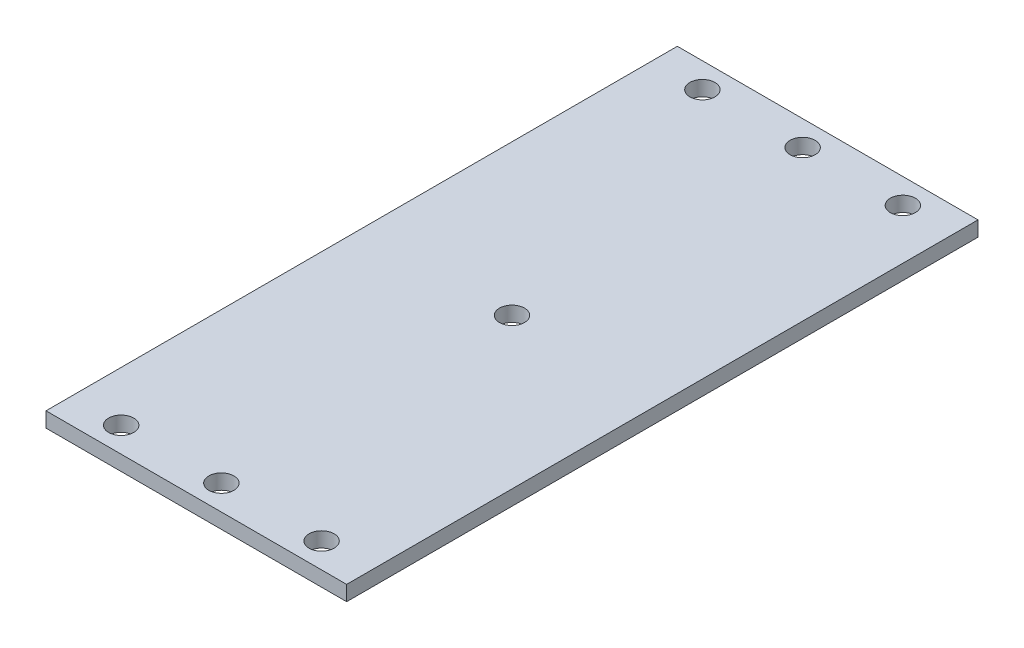
from build123d import *

# Parameters (mm, degrees)
SKETCH1_W           = 60
SKETCH1_H           = 126
BOSS_EXTRUDE1_DEPTH = 3
SKETCH2_R           = 2.5
CUT_EXTRUDE1_DEPTH  = 5


with BuildPart() as part:
    # Sketch1 → Boss-Extrude1 (new body)
    with BuildSketch(Plane(origin=(0, 0, 0), x_dir=(1, 0, 0), z_dir=(0, 1, 0))):
        Rectangle(SKETCH1_W, SKETCH1_H)
    extrude(amount=BOSS_EXTRUDE1_DEPTH)

    # Sketch2 → Cut-Extrude1 (cut)
    with BuildSketch(Plane(origin=(0, 3, 0), x_dir=(1, 0, 0), z_dir=(0, 1, 0))):
        with Locations((0, -58)):
            Circle(SKETCH2_R)
        with Locations((20, -58)):
            Circle(SKETCH2_R)
        with Locations((-20, -58)):
            Circle(SKETCH2_R)
        with Locations((20, 58)):
            Circle(SKETCH2_R)
        with Locations((0, 58)):
            Circle(SKETCH2_R)
        with Locations((-20, 58)):
            Circle(SKETCH2_R)
        Circle(SKETCH2_R)
    extrude(amount=-CUT_EXTRUDE1_DEPTH, mode=Mode.SUBTRACT)


solid = part.part
